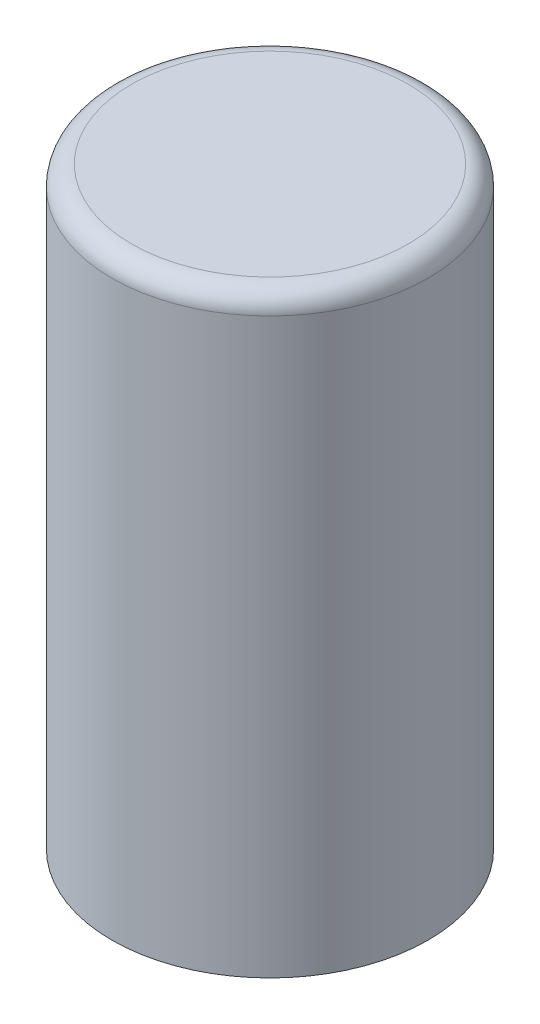
from build123d import *

# Parameters (mm, degrees)
SKETCH1_R           = 4
BOSS_EXTRUDE1_DEPTH = 15
FILLET1_R           = 0.5


with BuildPart() as part:
    # Sketch1 → Boss-Extrude1 (new body)
    with BuildSketch(Plane(origin=(0, 0, 0), x_dir=(1, 0, 0), z_dir=(0, 1, 0))):
        Circle(SKETCH1_R)
    extrude(amount=BOSS_EXTRUDE1_DEPTH)

    # Fillet1
    fillet1_edges = [part.edges().sort_by_distance(p)[0] for p in [
        (-4, 15, 0),
    ]]
    fillet(fillet1_edges, radius=FILLET1_R)


solid = part.part
